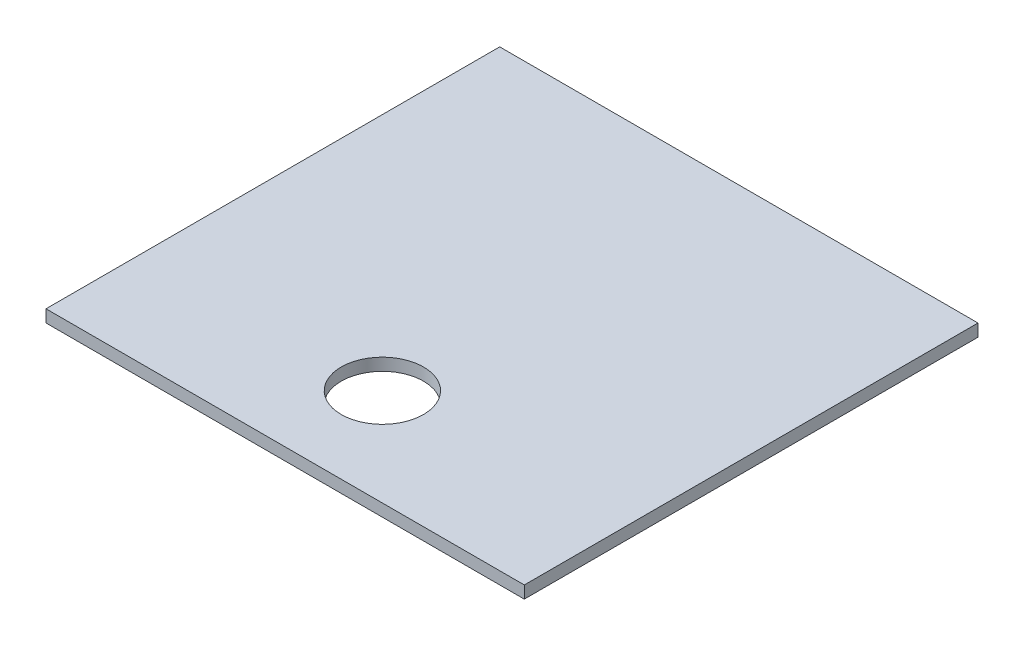
from build123d import *

# Parameters (mm, degrees)
CROQUIS1_W                 = 73.8
CROQUIS1_H                 = 70
SALIENTE_EXTRUIR1_DEPTH    = 1.9
CROQUIS2_R                 = 6.35
CORTAR_EXTRUIR1_DEPTH      = 1
CORTAR_EXTRUIR1_DEPTH_BACK = 2.9


with BuildPart() as part:
    # Croquis1 → Saliente-Extruir1 (new body)
    with BuildSketch(Plane(origin=(0, 0, 0), x_dir=(1, 0, 0), z_dir=(0, 1, 0))):
        Rectangle(CROQUIS1_W, CROQUIS1_H)
    extrude(amount=SALIENTE_EXTRUIR1_DEPTH)

    # Croquis2 → Cortar-Extruir1 (cut, two sides)
    with BuildSketch(Plane(origin=(0, 1.9, 0), x_dir=(1, 0, 0), z_dir=(0, 1, 0))) as cortar_extruir1_sk:
        with Locations((0, -20)):
            Circle(CROQUIS2_R)
    extrude(amount=CORTAR_EXTRUIR1_DEPTH, mode=Mode.SUBTRACT)
    extrude(cortar_extruir1_sk.sketch, amount=-CORTAR_EXTRUIR1_DEPTH_BACK, mode=Mode.SUBTRACT)


solid = part.part
